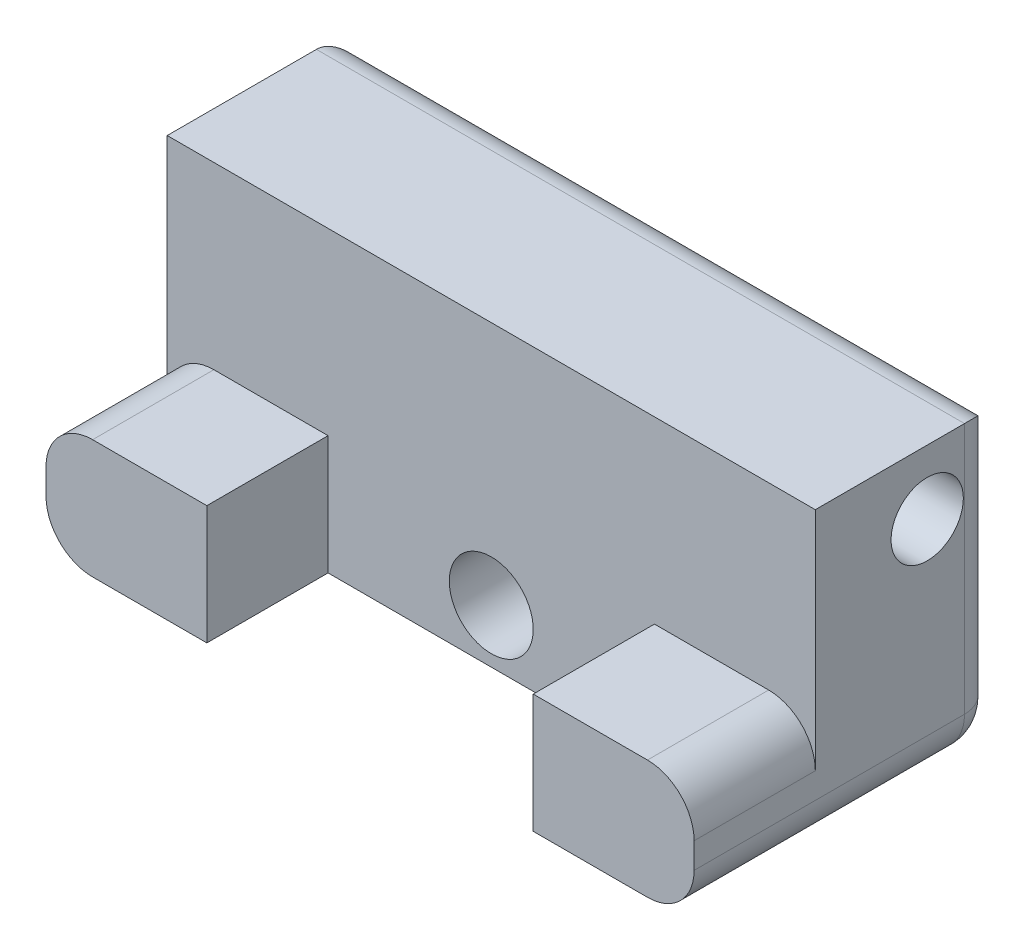
from build123d import *

# Parameters (mm, degrees)
SKETCH1_R                                           = 1.55
BOSS_EXTRUDE1_DEPTH                                 = 27.8
SKETCH2_W                                           = 14
SKETCH2_H                                           = 5.2
CUT_EXTRUDE1_DEPTH                                  = 6.8
CBORE_FOR_M3_HEX_SOCKET_HEAD_CAP_SCREW1_D           = 3.6
CBORE_FOR_M3_HEX_SOCKET_HEAD_CAP_SCREW1_CBORE_D     = 6.5
CBORE_FOR_M3_HEX_SOCKET_HEAD_CAP_SCREW1_CBORE_DEPTH = 3.4
SKETCH6_W                                           = 27.8
SKETCH6_H                                           = 13
CUT_EXTRUDE2_DEPTH                                  = 0.7
FILLET1_R                                           = 2
FILLET2_R                                           = 1.4


with BuildPart() as part:
    # Sketch1 → Boss-Extrude1 (new body)
    with BuildSketch(Plane(origin=(0, 0, 0), x_dir=(0, 0, -1), z_dir=(1, 0, 0))):
        Polygon((0, 0), (13, 0), (13, 13.5), (5.2, 13.5), (5.2, 5.8), (0, 5.8), align=None)
        with Locations((10, 10.75)):
            Circle(SKETCH1_R, mode=Mode.SUBTRACT)
    extrude(amount=BOSS_EXTRUDE1_DEPTH)

    # Sketch2 → Cut-Extrude1 (cut, through all)
    with BuildSketch(Plane(origin=(0, 5.8, 0), x_dir=(1, 0, 0), z_dir=(0, 1, 0))):
        with Locations((13.9, 2.6)):
            Rectangle(SKETCH2_W, SKETCH2_H)
    extrude(amount=-CUT_EXTRUDE1_DEPTH, mode=Mode.SUBTRACT)

    # CBORE for M3 Hex Socket Head Cap Screw1 (through all)
    with Locations(Plane(origin=(0, 0, -13), x_dir=(-1, 0, 0), z_dir=(0, 0, -1))):
        with Locations((-13.9, 3)):
            CounterBoreHole(CBORE_FOR_M3_HEX_SOCKET_HEAD_CAP_SCREW1_D / 2, CBORE_FOR_M3_HEX_SOCKET_HEAD_CAP_SCREW1_CBORE_D / 2, CBORE_FOR_M3_HEX_SOCKET_HEAD_CAP_SCREW1_CBORE_DEPTH)

    # Sketch6 → Cut-Extrude2 (cut)
    with BuildSketch(Plane.XZ):
        with Locations((13.9, -6.5)):
            Rectangle(SKETCH6_W, SKETCH6_H)
    extrude(amount=-CUT_EXTRUDE2_DEPTH, mode=Mode.SUBTRACT)

    # Fillet1
    fillet1_edges = [part.edges().sort_by_distance(p)[0] for p in [
        (27.8, 5.8, -2.6),
        (0, 0.7, -6.5),
        (27.8, 0.7, -6.5),
        (0, 5.8, -2.6),
    ]]
    fillet(fillet1_edges, radius=FILLET1_R)

    # Fillet2
    fillet2_edges = [part.edges().sort_by_distance(p)[0] for p in [
        (6.80190375, 0.7, -13),
        (0, 8.1, -13),
        (0.585786438, 1.285786438, -13),
        (27.214213562, 1.285786438, -13),
        (13.9, 13.5, -13),
        (13.9, 6.25, -13),
        (20.99809625, 0.7, -13),
        (27.8, 8.1, -13),
    ]]
    fillet(fillet2_edges, radius=FILLET2_R)


solid = part.part
